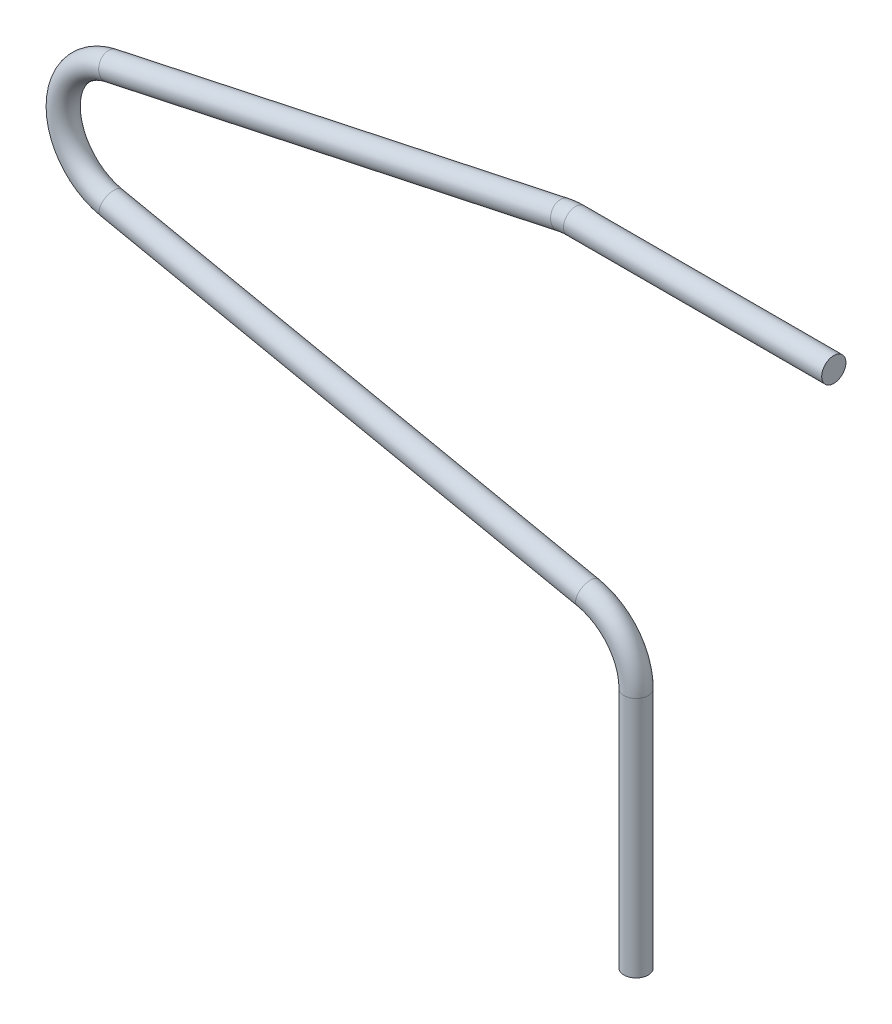
from build123d import *

# Parameters (mm, degrees)
SKIZZE2_R = 0.75


with BuildPart() as part:
    # Austragung1: sweep along a path in Skizze1
    with BuildLine(Plane.XY) as austragung1_path:
        Line((0, 0), (0, 15))
        ThreePointArc((0, 15), (-0.840264248, 17.365573473), (-2.98450019, 18.671036644))
        Line((-2.98450019, 18.671036644), (-32.51549981, 24.828963356))
        ThreePointArc((-32.51549981, 24.828963356), (-35.499985743, 28.489659261), (-32.535734083, 32.166759053))
        Line((-32.535734083, 32.166759053), (-4.535734083, 38.166759053))
        ThreePointArc((-4.535734083, 38.166759053), (-4.145065534, 38.229131698), (-3.75, 38.25))
        Line((-3.75, 38.25), (12.25, 38.25))
    # Skizze2 → Austragung1 (sweep)
    with BuildSketch(Plane(origin=(0, 0, 0), x_dir=(1, 0, 0), z_dir=(0, 1, 0))):
        Circle(SKIZZE2_R)
    sweep(path=austragung1_path.line)


solid = part.part
